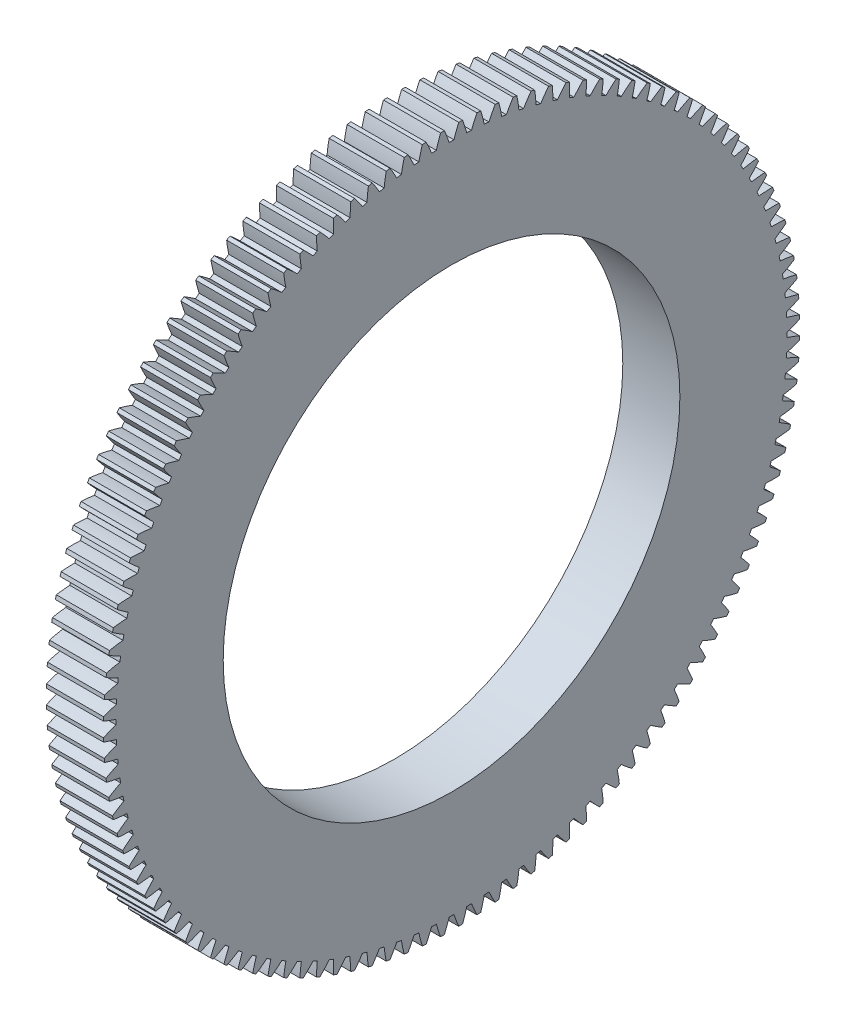
from build123d import *

# Parameters (mm, degrees)
BASPROSKE_W     = 12.7
BASPROSKE_H     = 77.47
TOOTHCUT_DEPTH  = 111.292754975
TEETHCUTS_COUNT = 120
TEETHCUTS_ANGLE = 357
BORSKE_R        = 50.8
BORE_DEPTH      = 50.8000508


with BuildPart() as part:
    # BasProSke → Base-Revolve (revolve)
    with BuildSketch(Plane(origin=(0, 0, 0), x_dir=(1, 0, 0), z_dir=(0, 1, 0)), mode=Mode.PRIVATE) as base_revolve_sk:
        with Locations((6.35, 38.735)):
            Rectangle(BASPROSKE_W, BASPROSKE_H)
    revolve(base_revolve_sk.sketch.rotate(Axis((-10, 0, 0), (1, 0, 0)), 180), axis=Axis((-10, 0, 0), (1, 0, 0)))

    # TooCutSke → ToothCut (cut, through all)
    with BuildSketch(Plane(origin=(0, 0, 0), x_dir=(0, 0, -1), z_dir=(1, 0, 0))):
        with BuildLine():
            ThreePointArc((0.530468489, 74.623314575), (0, 74.6252), (-0.530468489, 74.623314575))
            ThreePointArc((-0.530468489, 74.623314575), (-1.037441082, 76.064538991), (-1.615994644, 77.478549176))
            ThreePointArc((-1.615994644, 77.478549176), (0, 77.4954), (1.615994644, 77.478549176))
            ThreePointArc((1.615994644, 77.478549176), (1.037441082, 76.064538991), (0.530468489, 74.623314575))
        make_face()
    toothcut = extrude(amount=TOOTHCUT_DEPTH, mode=Mode.SUBTRACT)

    # TeethCuts: ToothCut ×120 about axis
    teethcuts_axis = Axis((-10, 0, 0), (1, 0, 0))
    for i in range(1, TEETHCUTS_COUNT):
        add(toothcut.rotate(teethcuts_axis, i * TEETHCUTS_ANGLE / (TEETHCUTS_COUNT - 1)), mode=Mode.SUBTRACT)

    # BorSke → Bore (cut, symmetric)
    with BuildSketch(Plane(origin=(0, 0, 0), x_dir=(0, 0, -1), z_dir=(1, 0, 0))):
        with Locations(Location((0, 0, 0), (0, 0, 180))):
            Circle(BORSKE_R)
    extrude(amount=BORE_DEPTH, both=True, mode=Mode.SUBTRACT)


solid = part.part
